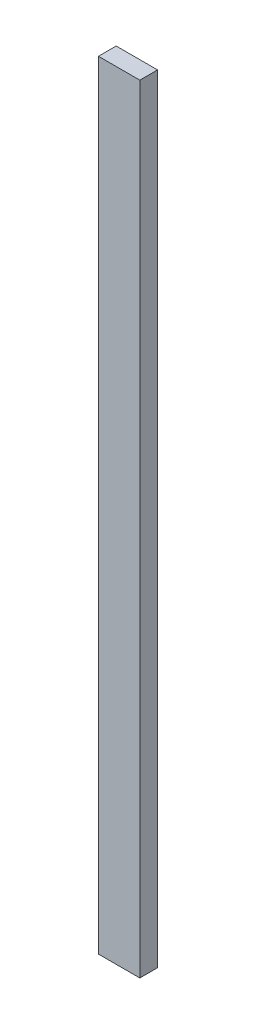
from build123d import *

# Parameters (mm, degrees)
SKETCH1_W           = 88.9
SKETCH1_H           = 38.1
BOSS_EXTRUDE1_DEPTH = 1670.05


with BuildPart() as part:
    # Sketch1 → Boss-Extrude1 (new body)
    with BuildSketch(Plane(origin=(0, 0, 0), x_dir=(1, 0, 0), z_dir=(0, 1, 0))):
        Rectangle(SKETCH1_W, SKETCH1_H)
    extrude(amount=BOSS_EXTRUDE1_DEPTH)


solid = part.part
